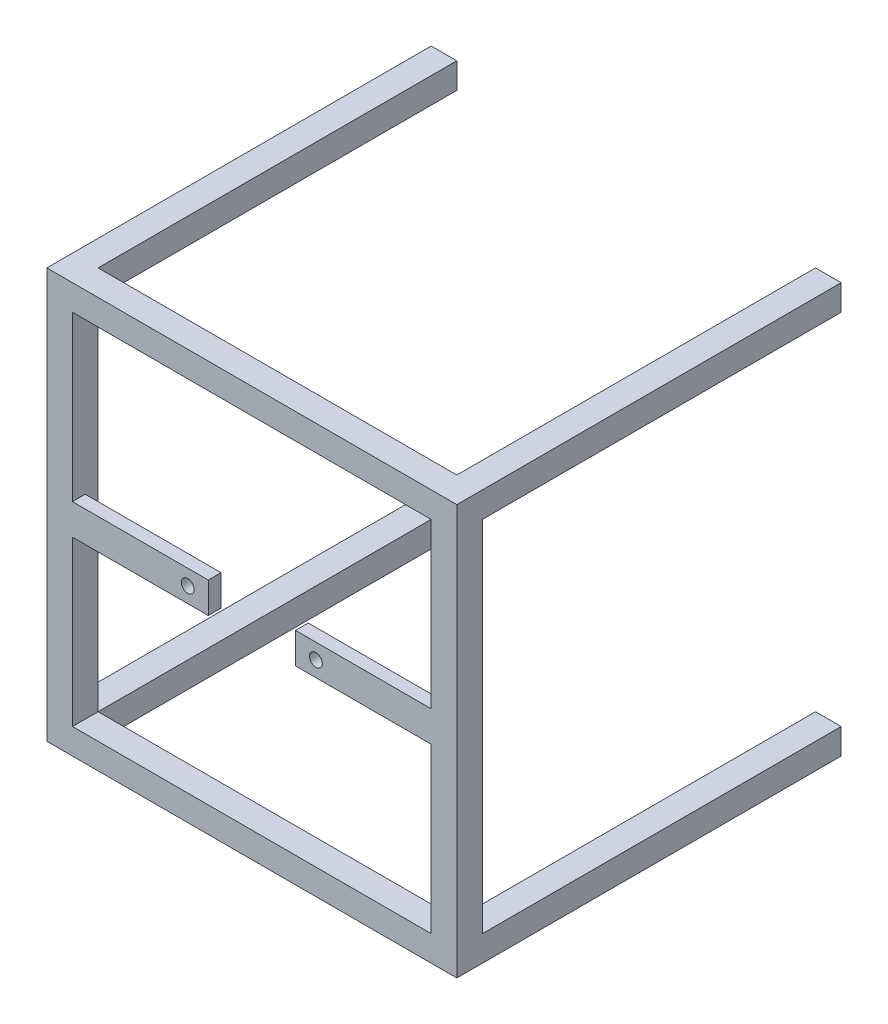
from build123d import *

# Parameters (mm, degrees)
CROQUIS2_W                   = 160
CROQUIS2_H                   = 160
CROQUIS2_W_2                 = 140
CROQUIS2_H_2                 = 140
SALIENTE_EXTRUIR1_DEPTH      = 10
CROQUIS3_W                   = 152
CROQUIS3_H                   = 152
CROQUIS3_W_2                 = 148
CROQUIS3_H_2                 = 148
CORTAR_EXTRUIR1_DEPTH        = 3.5
SALIENTE_EXTRUIR2_DEPTH      = 140
SALIENTE_EXTRUIR2_DEPTH_BACK = 10
CROQUIS4_W                   = 10
CROQUIS4_H                   = 10
CROQUIS7_W                   = 160
CROQUIS7_H                   = 160
CROQUIS7_W_2                 = 140
CROQUIS7_H_2                 = 140
SALIENTE_EXTRUIR3_DEPTH      = 10
CROQUIS8_W                   = 63
CROQUIS8_H                   = 12
CROQUIS8_R                   = 2.5
SALIENTE_EXTRUIR4_DEPTH      = 5
CROQUIS9_W                   = 10
CROQUIS9_H                   = 160
CORTAR_EXTRUIR2_DEPTH        = 278.128129211
CROQUIS10_R                  = 2.5
CORTAR_EXTRUIR3_DEPTH        = 5


with BuildPart() as part:
    # Croquis2 → Saliente-Extruir1 (new body)
    with BuildSketch(Plane.XY):
        with Locations((80, -80)):
            Rectangle(CROQUIS2_W, CROQUIS2_H)
        with Locations((80, -80)):
            Rectangle(CROQUIS2_W_2, CROQUIS2_H_2, mode=Mode.SUBTRACT)
    extrude(amount=SALIENTE_EXTRUIR1_DEPTH)

    # Croquis3 → Cortar-Extruir1 (cut)
    with BuildSketch(Plane.XY.offset(10)):
        with Locations((80, -80)):
            Rectangle(CROQUIS3_W, CROQUIS3_H)
        with Locations((80, -80)):
            Rectangle(CROQUIS3_W_2, CROQUIS3_H_2, mode=Mode.SUBTRACT)
    extrude(amount=-CORTAR_EXTRUIR1_DEPTH, mode=Mode.SUBTRACT)

    # Croquis4 → Saliente-Extruir2 (add, two sides: drawn at the far end of the back side and taken through both)
    with BuildSketch(Plane.XY.offset(10).offset(-SALIENTE_EXTRUIR2_DEPTH_BACK)):
        with Locations((5, -5)):
            Rectangle(CROQUIS4_W, CROQUIS4_H)
        with Locations((155, -5)):
            Rectangle(CROQUIS4_W, CROQUIS4_H)
        with Locations((155, -155)):
            Rectangle(CROQUIS4_W, CROQUIS4_H)
        with Locations((5, -155)):
            Rectangle(CROQUIS4_W, CROQUIS4_H)
    extrude(amount=SALIENTE_EXTRUIR2_DEPTH + SALIENTE_EXTRUIR2_DEPTH_BACK)

    # Croquis7 → Saliente-Extruir3 (add)
    with BuildSketch(Plane.XY.offset(150)):
        with Locations((80, -80)):
            Rectangle(CROQUIS7_W, CROQUIS7_H)
        with Locations((80, -80)):
            Rectangle(CROQUIS7_W_2, CROQUIS7_H_2, mode=Mode.SUBTRACT)
    extrude(amount=SALIENTE_EXTRUIR3_DEPTH)

    # Croquis8 → Saliente-Extruir4 (add)
    # profile 1 of 2: a face of its own
    with BuildSketch(Plane.XY.offset(160)):
        with Locations((31.5, -80)):
            Rectangle(CROQUIS8_W, CROQUIS8_H)
        with Locations((55, -80)):
            Circle(CROQUIS8_R, mode=Mode.SUBTRACT)
    # profile 2 of 2: a face of its own
    with BuildSketch(Plane.XY.offset(160)):
        with Locations((128.5, -80)):
            Rectangle(CROQUIS8_W, CROQUIS8_H)
        with Locations((105, -80)):
            Circle(CROQUIS8_R, mode=Mode.SUBTRACT)
    extrude(amount=-SALIENTE_EXTRUIR4_DEPTH)

    # Croquis9 → Cortar-Extruir2 (cut, through all)
    with BuildSketch(Plane.ZY):
        with Locations((5, -80)):
            Rectangle(CROQUIS9_W, CROQUIS9_H)
    extrude(amount=-CORTAR_EXTRUIR2_DEPTH, mode=Mode.SUBTRACT)

    # Croquis10 → Cortar-Extruir3 (cut)
    with BuildSketch(Plane(origin=(0, 0, 10), x_dir=(-1, 0, 0), z_dir=(0, 0, -1))):
        with Locations((-155, -155)):
            Circle(CROQUIS10_R)
        with Locations((-5, -5)):
            Circle(CROQUIS10_R)
        with Locations((-155, -5)):
            Circle(CROQUIS10_R)
        with Locations((-5, -155)):
            Circle(CROQUIS10_R)
    extrude(amount=-CORTAR_EXTRUIR3_DEPTH, mode=Mode.SUBTRACT)


solid = part.part
